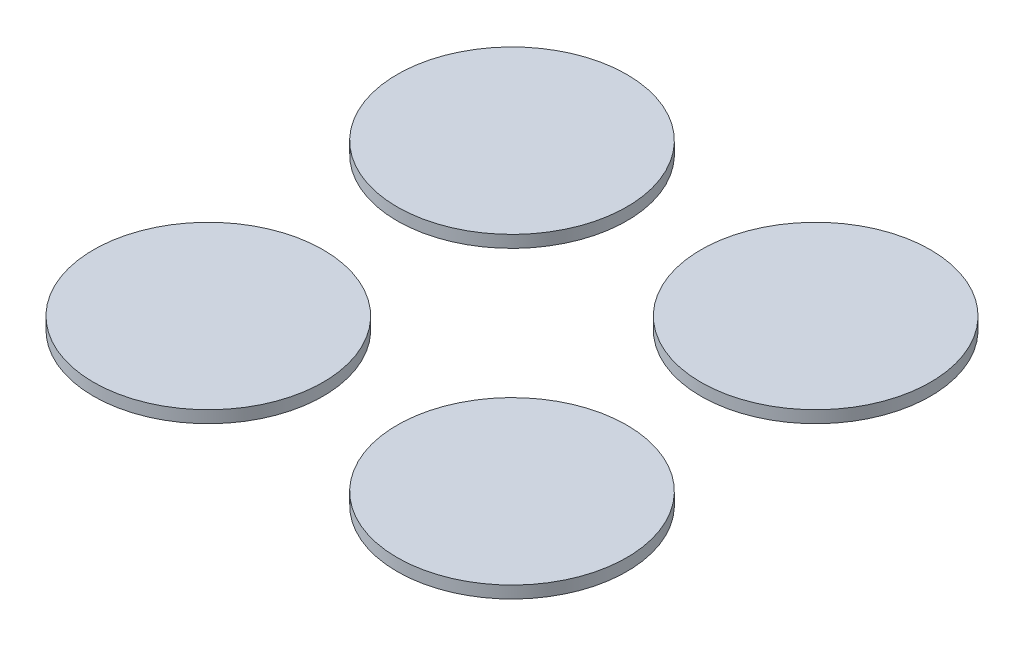
from build123d import *

# Parameters (mm, degrees)
SKETCH1_R             = 23.02
BOSS_EXTRUDE1_DEPTH   = 2.43
BOSS_EXTRUDE1_2_DEPTH = 2.43
BOSS_EXTRUDE1_3_DEPTH = 2.43
BOSS_EXTRUDE1_4_DEPTH = 2.43


with BuildPart() as part:
    # Sketch1 → Boss-Extrude1 (new body)
    with BuildSketch(Plane(origin=(0, 0, 0), x_dir=(1, 0, 0), z_dir=(0, 1, 0))):
        with Locations((-30.445, 30.445)):
            Circle(SKETCH1_R)
    extrude(amount=BOSS_EXTRUDE1_DEPTH)


with BuildPart() as body_2:
    # Sketch1 → Boss-Extrude1 2 (new body)
    with BuildSketch(Plane(origin=(0, 0, 0), x_dir=(1, 0, 0), z_dir=(0, 1, 0))):
        with Locations((30.445, 30.445)):
            Circle(SKETCH1_R)
    extrude(amount=BOSS_EXTRUDE1_2_DEPTH)


with BuildPart() as body_3:
    # Sketch1 → Boss-Extrude1 3 (new body)
    with BuildSketch(Plane(origin=(0, 0, 0), x_dir=(1, 0, 0), z_dir=(0, 1, 0))):
        with Locations((30.445, -30.445)):
            Circle(SKETCH1_R)
    extrude(amount=BOSS_EXTRUDE1_3_DEPTH)


with BuildPart() as body_4:
    # Sketch1 → Boss-Extrude1 4 (new body)
    with BuildSketch(Plane(origin=(0, 0, 0), x_dir=(1, 0, 0), z_dir=(0, 1, 0))):
        with Locations((-30.445, -30.445)):
            Circle(SKETCH1_R)
    extrude(amount=BOSS_EXTRUDE1_4_DEPTH)


solid = Compound([part.part, body_2.part, body_3.part, body_4.part])
